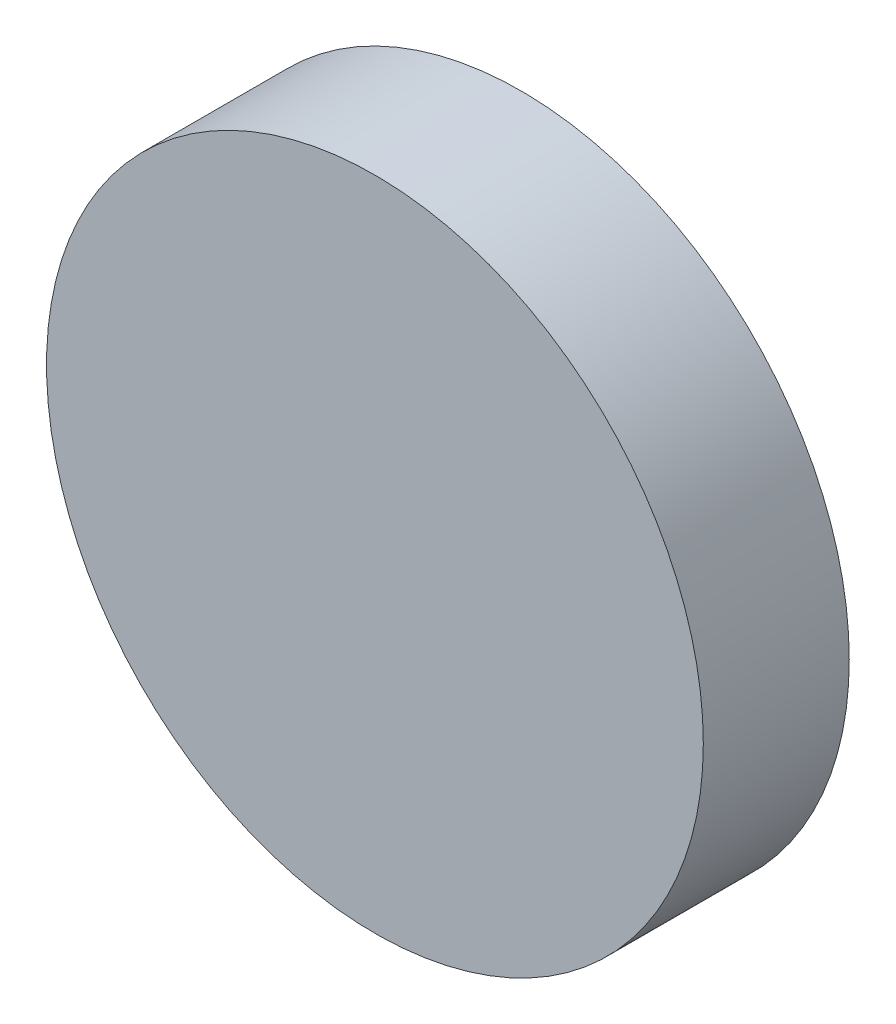
from build123d import *

# Parameters (mm, degrees)
SKETCH2_R           = 11.43
BOSS_EXTRUDE1_DEPTH = 5.08


with BuildPart() as part:
    # Sketch2 → Boss-Extrude1 (new body)
    with BuildSketch(Plane.XY):
        Circle(SKETCH2_R)
    extrude(amount=BOSS_EXTRUDE1_DEPTH)


solid = part.part
